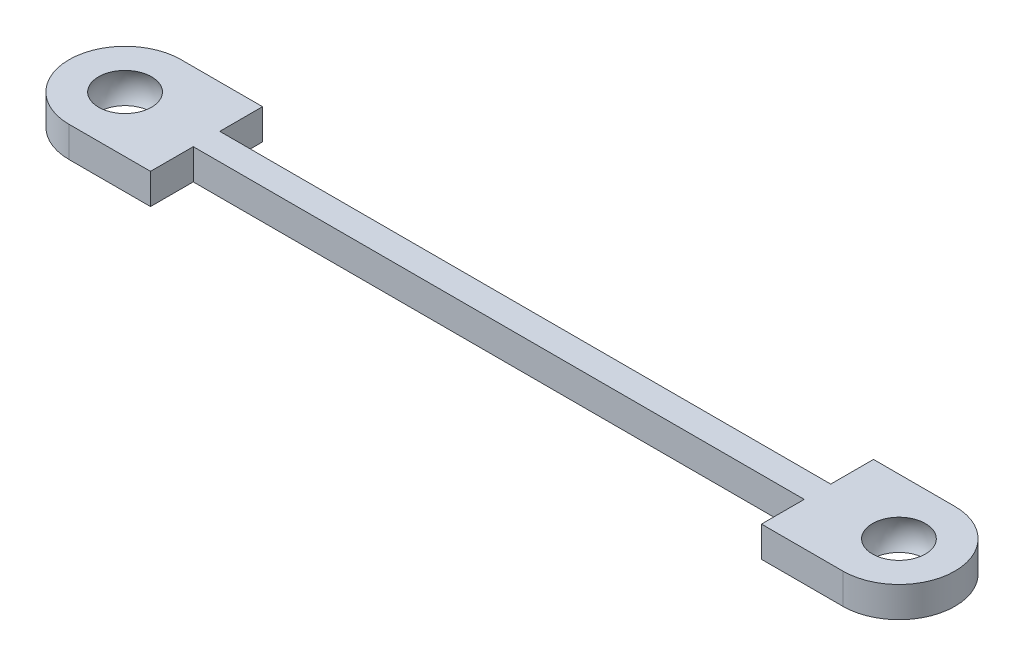
from build123d import *

# Parameters (mm, degrees)
BOSS_EXTRUDE1_DEPTH      = 0.75
BOSS_EXTRUDE1_DEPTH_BACK = 0.75


with BuildPart() as part:
    # Sketch1 → Boss-Extrude1 (new, two sides: drawn at the far end of the back side and taken through both)
    with BuildSketch(Plane(origin=(0, 0, 0), x_dir=(1, 0, 0), z_dir=(0, 1, 0)).offset(-BOSS_EXTRUDE1_DEPTH_BACK)):
        with BuildLine():
            Line((-15, 2.75), (-19, 2.75))
            ThreePointArc((-19, 2.75), (-21.75, 0), (-19, -2.75))
            Line((-19, -2.75), (-15, -2.75))
            Line((-15, -2.75), (-15, -0.650720727))
            Line((-15, -0.650720727), (15, -0.650720727))
            Line((15, -0.650720727), (15, -2.75))
            Line((15, -2.75), (19, -2.75))
            ThreePointArc((19, -2.75), (21.75, 0), (19, 2.75))
            Line((19, 2.75), (15, 2.75))
            Line((15, 2.75), (15, 0.650720727))
            Line((15, 0.650720727), (-15, 0.650720727))
            Line((-15, 0.650720727), (-15, 2.75))
        make_face()
    extrude(amount=BOSS_EXTRUDE1_DEPTH + BOSS_EXTRUDE1_DEPTH_BACK)

    # Sketch1_3 → Cut-Revolve1 (revolve, cut)
    with BuildSketch(Plane(origin=(0, 0, 0), x_dir=(1, 0, 0), z_dir=(0, 1, 0))):
        with BuildLine():
            Line((-17.5, 0), (-20.5, 0))
            ThreePointArc((-20.5, 0), (-19, -1.5), (-17.5, 0))
        make_face()
        with BuildLine():
            Line((20.5, 0), (17.5, 0))
            ThreePointArc((17.5, 0), (19, -1.5), (20.5, 0))
        make_face()
    revolve(axis=Axis((-19, 0, 0), (1, 0, 0)), mode=Mode.SUBTRACT)


solid = part.part
